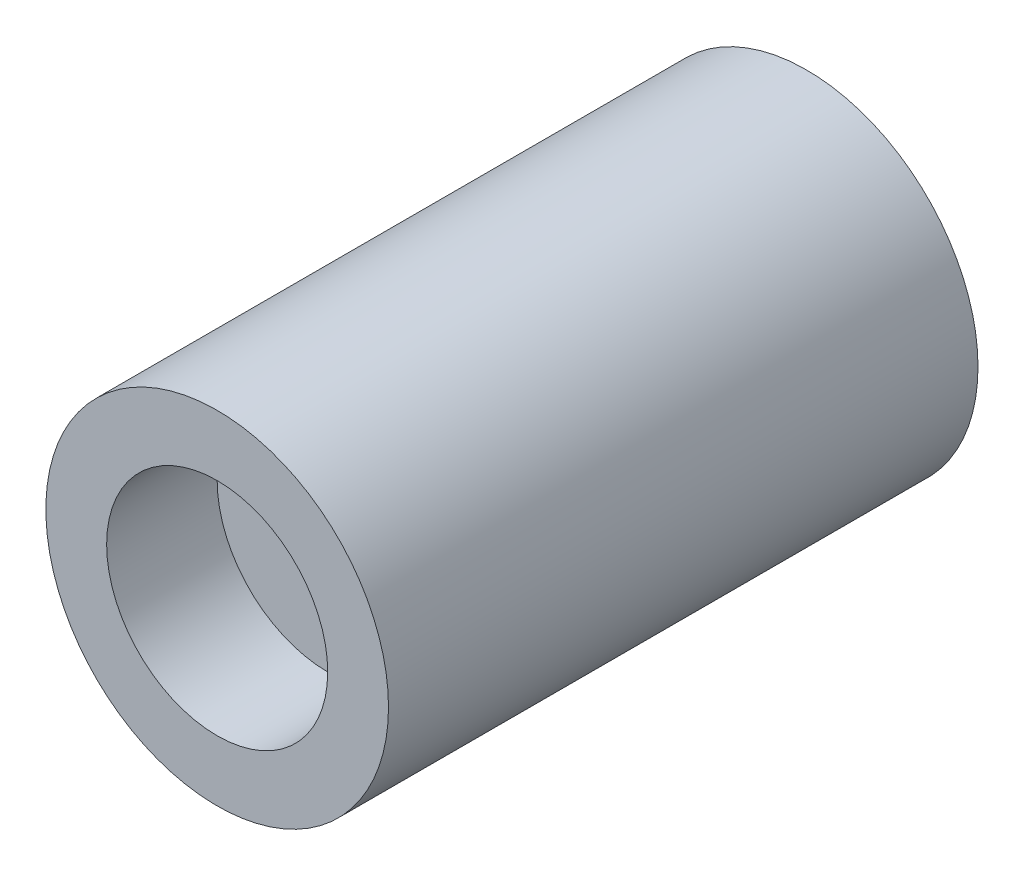
from build123d import *

# Parameters (mm, degrees)
SKETCH1_R           = 23.25
BOSS_EXTRUDE1_DEPTH = 80
SKETCH2_R           = 15
CUT_EXTRUDE4_DEPTH  = 15


with BuildPart() as part:
    # Sketch1 → Boss-Extrude1 (new body)
    with BuildSketch(Plane.XY):
        Circle(SKETCH1_R)
    extrude(amount=BOSS_EXTRUDE1_DEPTH)

    # Sketch2 → Cut-Extrude4 (cut)
    with BuildSketch(Plane.XY.offset(80)):
        Circle(SKETCH2_R)
    extrude(amount=-CUT_EXTRUDE4_DEPTH, mode=Mode.SUBTRACT)


solid = part.part
